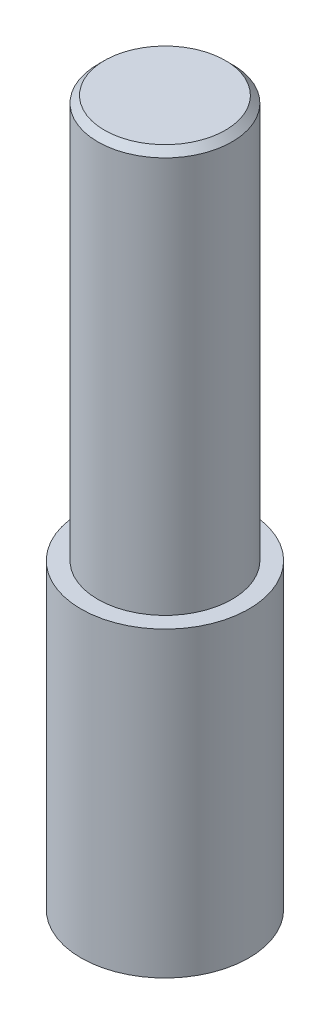
from build123d import *

# Parameters (mm, degrees)
SKETCH1_R           = 12.5
BOSS_EXTRUDE1_DEPTH = 45
SKETCH2_R           = 10
BOSS_EXTRUDE2_DEPTH = 60
CHAMFER1_SIZE       = 1


with BuildPart() as part:
    # Sketch1 → Boss-Extrude1 (new body)
    with BuildSketch(Plane(origin=(0, 0, 0), x_dir=(1, 0, 0), z_dir=(0, 1, 0))):
        Circle(SKETCH1_R)
    extrude(amount=BOSS_EXTRUDE1_DEPTH)

    # Sketch2 → Boss-Extrude2 (add)
    with BuildSketch(Plane(origin=(0, 45, 0), x_dir=(1, 0, 0), z_dir=(0, 1, 0))):
        Circle(SKETCH2_R)
    extrude(amount=BOSS_EXTRUDE2_DEPTH)

    # Chamfer1
    chamfer1_edges = [part.edges().sort_by_distance(p)[0] for p in [
        (-10, 105, 0),
    ]]
    chamfer(chamfer1_edges, length=CHAMFER1_SIZE)


solid = part.part
